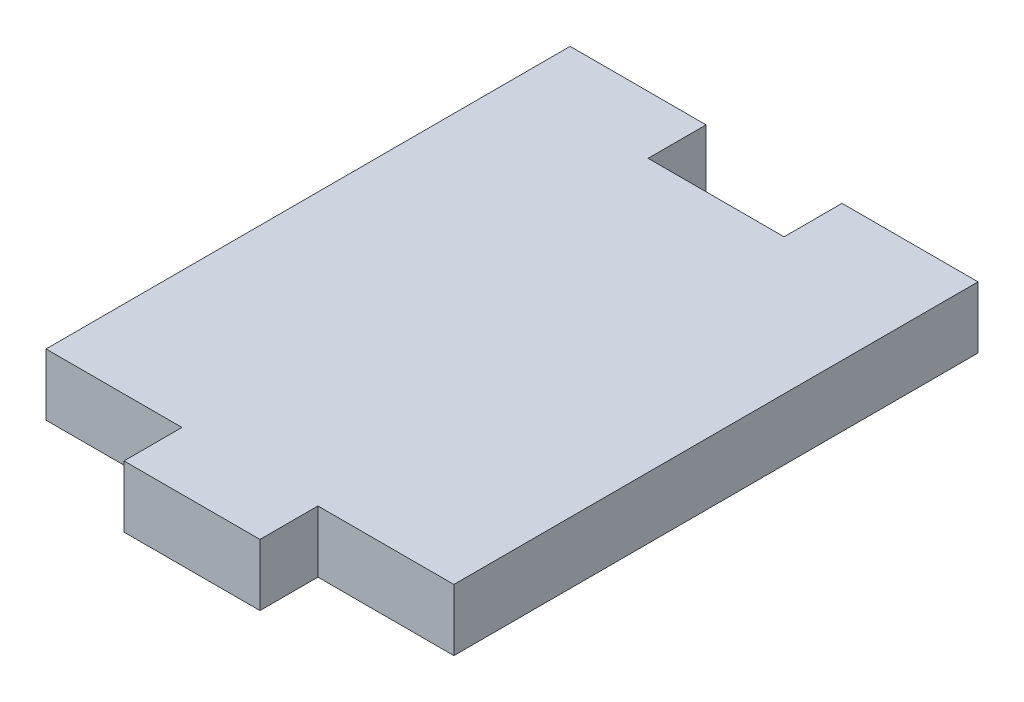
from build123d import *

# Parameters (mm, degrees)
BOSS_EXTRUDE1_DEPTH = 6.35


with BuildPart() as part:
    # Sketch1 → Boss-Extrude1 (new body)
    with BuildSketch(Plane(origin=(0, 0, 0), x_dir=(1, 0, 0), z_dir=(0, 1, 0))):
        Polygon((14, 48), (14, 53.969), (0, 53.969), (0, 48), (0, 0), (14, 0), (14, -5.969), (28, -5.969), (28, 0), (42, 0), (42, 48), (42, 53.969), (28, 53.969), (28, 48), align=None)
    extrude(amount=BOSS_EXTRUDE1_DEPTH)


solid = part.part
